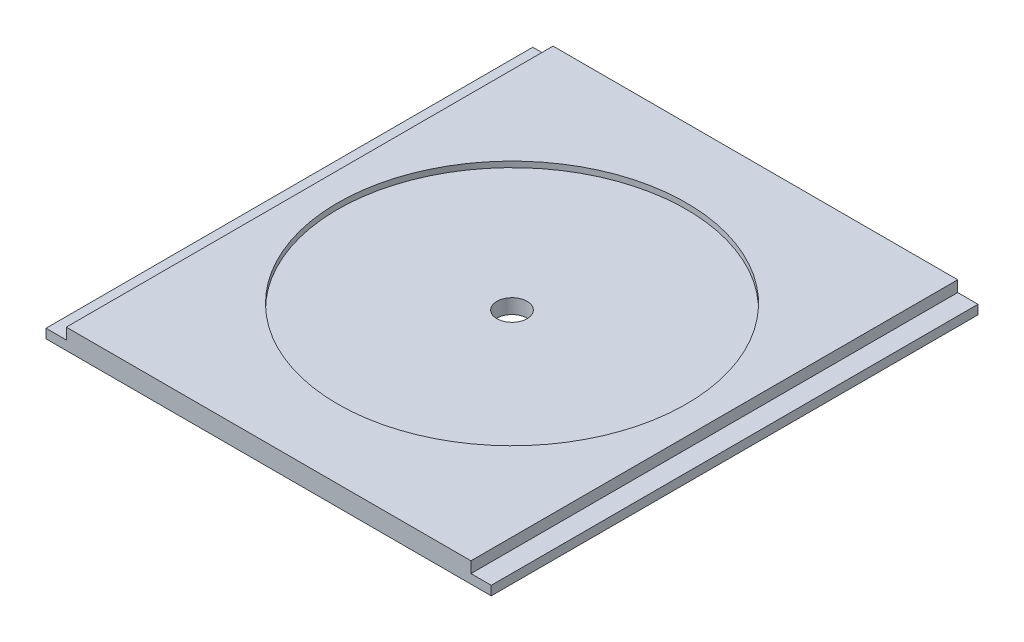
from build123d import *

# Parameters (mm, degrees)
SKETCH1_W           = 139.40028
SKETCH1_H           = 152.4
BOSS_EXTRUDE1_DEPTH = 6.35
SKETCH2_W           = 6.35
SKETCH2_H           = 152.4
CUT_EXTRUDE1_DEPTH  = 3.47472
SKETCH3_R           = 54.58206
CUT_EXTRUDE2_DEPTH  = 1.778
SKETCH4_R           = 4.72186
CUT_EXTRUDE3_DEPTH  = 5.572


with BuildPart() as part:
    # Sketch1 → Boss-Extrude1 (new body)
    with BuildSketch(Plane(origin=(0, 0, 0), x_dir=(1, 0, 0), z_dir=(0, 1, 0))):
        with Locations((69.70014, 76.2)):
            Rectangle(SKETCH1_W, SKETCH1_H)
    extrude(amount=BOSS_EXTRUDE1_DEPTH)

    # Sketch2 → Cut-Extrude1 (cut)
    with BuildSketch(Plane(origin=(0, 6.35, 0), x_dir=(1, 0, 0), z_dir=(0, 1, 0))):
        with Locations((3.175, 76.2)):
            Rectangle(SKETCH2_W, SKETCH2_H)
        with Locations((136.22528, 76.2)):
            Rectangle(SKETCH2_W, SKETCH2_H)
    extrude(amount=-CUT_EXTRUDE1_DEPTH, mode=Mode.SUBTRACT)

    # Sketch3 → Cut-Extrude2 (cut)
    with BuildSketch(Plane(origin=(0, 6.35, 0), x_dir=(1, 0, 0), z_dir=(0, 1, 0))):
        with Locations((69.70014, 76.2)):
            Circle(SKETCH3_R)
    extrude(amount=-CUT_EXTRUDE2_DEPTH, mode=Mode.SUBTRACT)

    # Sketch4 → Cut-Extrude3 (cut, through all)
    with BuildSketch(Plane(origin=(0, 4.572, 0), x_dir=(1, 0, 0), z_dir=(0, 1, 0))):
        with Locations((69.70014, 76.2)):
            Circle(SKETCH4_R)
    extrude(amount=-CUT_EXTRUDE3_DEPTH, mode=Mode.SUBTRACT)


solid = part.part
